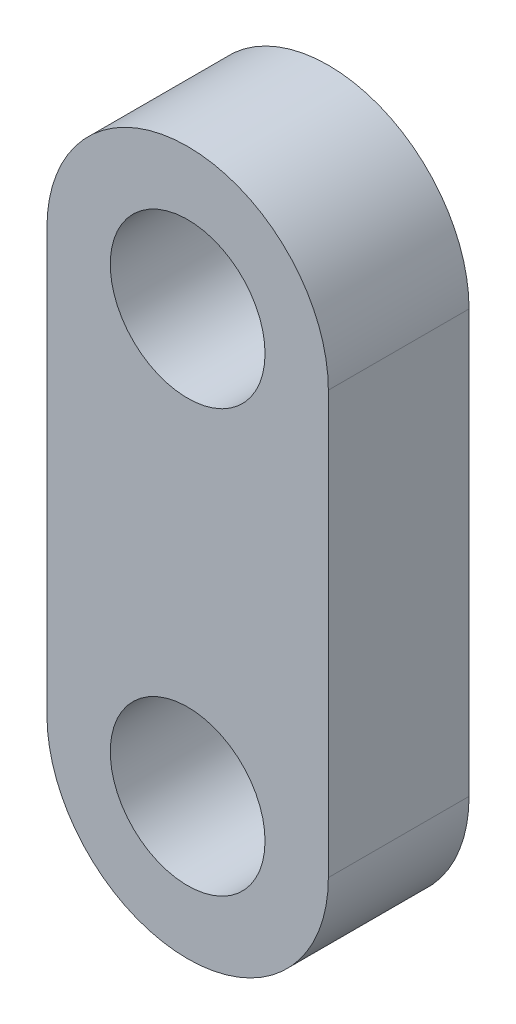
from build123d import *

# Parameters (mm, degrees)
BOSS_EXTRUDE1_DEPTH  = 5
M5_CLEARANCE_HOLE1_D = 5.5


with BuildPart() as part:
    # Sketch1 → Boss-Extrude1 (new body)
    with BuildSketch(Plane.XY):
        with BuildLine():
            Line((5, 7.5), (5, -7.5))
            ThreePointArc((5, -7.5), (0, -12.5), (-5, -7.5))
            Line((-5, -7.5), (-5, 7.5))
            ThreePointArc((-5, 7.5), (0, 12.5), (5, 7.5))
        make_face()
    extrude(amount=BOSS_EXTRUDE1_DEPTH)

    # M5 Clearance Hole1 (through all)
    with Locations(Plane.XY.offset(5)):
        with Locations((0, 7.5), (0, -7.5)):
            Hole(M5_CLEARANCE_HOLE1_D / 2)


solid = part.part
